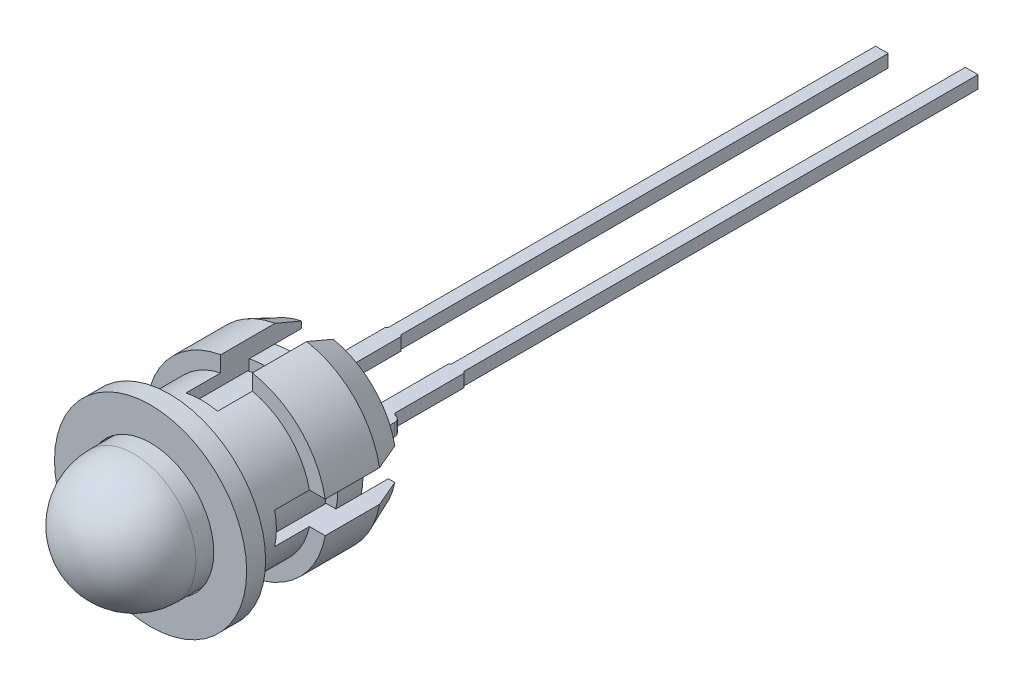
from build123d import *

# Parameters (mm, degrees)
EXTRUDE1_DEPTH          = 0.254
EXTRUDE1_DEPTH_BACK     = 0.254
CUT_EXTRUDE_THIN2_START = -27.675950193
SKETCH5_W               = 1.27
SKETCH5_H               = 8.860157491
CUT_EXTRUDE_THIN2_DEPTH = 31.231950193
CIRPATTERN2_COUNT       = 2
CIRPATTERN2_ANGLE       = 90


with BuildPart() as part:
    # Sketch1 → Revolve1 (revolve)
    with BuildSketch(Plane(origin=(0, 0, 0), x_dir=(0, 0, -1), z_dir=(1, 0, 0))):
        with BuildLine():
            Line((0, 0), (0, 2.921))
            Line((0, 2.921), (-1.016, 2.921))
            Line((-1.016, 2.921), (-1.016, 2.5))
            Line((-1.016, 2.5), (-6.2884, 2.5))
            ThreePointArc((-6.2884, 2.5), (-8.056166953, 1.767766953), (-8.7884, 0))
            Line((-8.7884, 0), (0, 0))
        make_face()
    revolve(axis=Axis((0, 0, 68.7324), (0, 0, -1)))

    # Sketch3 → Extrude1 (add, two sides: drawn at the far end of the back side and taken through both)
    with BuildSketch(Plane(origin=(0, 0, 0), x_dir=(1, 0, 0), z_dir=(0, 1, 0)).offset(-EXTRUDE1_DEPTH_BACK)):
        with BuildLine():
            Line((0.8382, 0), (1.7018, 0))
            Line((1.7018, 0), (1.7018, 1.740996518))
            ThreePointArc((1.7018, 1.740996518), (1.720043698, 1.806579036), (1.769533333, 1.853319544))
            ThreePointArc((1.769533333, 1.853319544), (1.868512605, 1.946800561), (1.905, 2.077965597))
            Line((1.905, 2.077965597), (1.905, 2.289552623))
            ThreePointArc((1.905, 2.289552623), (1.844995704, 2.453508918), (1.693333333, 2.54))
            ThreePointArc((1.693333333, 2.54), (1.617502148, 2.583245541), (1.5875, 2.665223689))
            Line((1.5875, 2.665223689), (1.5875, 5.3975))
            Line((1.5875, 5.3975), (1.524, 5.461))
            Line((1.524, 5.461), (1.524, 26.1112))
            Line((1.524, 26.1112), (1.016, 26.1112))
            Line((1.016, 26.1112), (1.016, 5.461))
            Line((1.016, 5.461), (0.9525, 5.3975))
            Line((0.9525, 5.3975), (0.9525, 2.665223689))
            ThreePointArc((0.9525, 2.665223689), (0.922497852, 2.583245541), (0.846666667, 2.54))
            ThreePointArc((0.846666667, 2.54), (0.695004296, 2.453508918), (0.635, 2.289552623))
            Line((0.635, 2.289552623), (0.635, 2.077965597))
            ThreePointArc((0.635, 2.077965597), (0.671487395, 1.946800561), (0.770466667, 1.853319544))
            ThreePointArc((0.770466667, 1.853319544), (0.819956302, 1.806579036), (0.8382, 1.740996518))
            Line((0.8382, 1.740996518), (0.8382, 0))
        make_face()
        with BuildLine():
            Line((-1.5875, 5.3975), (-1.524, 5.461))
            Line((-1.524, 5.461), (-1.524, 25.0444))
            Line((-1.524, 25.0444), (-1.016, 25.0444))
            Line((-1.016, 25.0444), (-1.016, 5.461))
            Line((-1.016, 5.461), (-0.9525, 5.3975))
            Line((-0.9525, 5.3975), (-0.9525, 2.665223689))
            ThreePointArc((-0.9525, 2.665223689), (-0.922497852, 2.583245541), (-0.846666667, 2.54))
            ThreePointArc((-0.846666667, 2.54), (-0.695004296, 2.453508918), (-0.635, 2.289552623))
            Line((-0.635, 2.289552623), (-0.635, 2.077965597))
            ThreePointArc((-0.635, 2.077965597), (-0.671487395, 1.946800561), (-0.770466667, 1.853319544))
            ThreePointArc((-0.770466667, 1.853319544), (-0.819956302, 1.806579036), (-0.8382, 1.740996518))
            Line((-0.8382, 1.740996518), (-0.8382, 0))
            Line((-0.8382, 0), (-1.7018, 0))
            Line((-1.7018, 0), (-1.7018, 1.740996518))
            ThreePointArc((-1.7018, 1.740996518), (-1.720043698, 1.806579036), (-1.769533333, 1.853319544))
            ThreePointArc((-1.769533333, 1.853319544), (-1.868512605, 1.946800561), (-1.905, 2.077965597))
            Line((-1.905, 2.077965597), (-1.905, 2.289552623))
            ThreePointArc((-1.905, 2.289552623), (-1.844995704, 2.453508918), (-1.693333333, 2.54))
            ThreePointArc((-1.693333333, 2.54), (-1.617502148, 2.583245541), (-1.5875, 2.665223689))
            Line((-1.5875, 2.665223689), (-1.5875, 5.3975))
        make_face()
    extrude(amount=EXTRUDE1_DEPTH + EXTRUDE1_DEPTH_BACK)


with BuildPart() as body_2:
    # Sketch4 → Revolve3 (revolve)
    with BuildSketch(Plane(origin=(0, 0, 0), x_dir=(0, 0, -1), z_dir=(1, 0, 0))):
        Polygon((-5.6134, 3.8608), (-5.6134, 2.54), (-1.016, 2.54), (-1.016, 2.921), (1.0922, 2.921), (1.0922, 3.175), (0.0254, 3.6195), (-2.159, 3.6195), (-2.159, 2.9972), (-4.8514, 2.9972), (-4.8514, 3.8608), align=None)
    revolve(axis=Axis((0, 0, 10.223161333), (0, 0, -1)))

    # Sketch5 → Cut-Extrude-Thin2 (cut)
    with BuildSketch(Plane.XY.offset(CUT_EXTRUDE_THIN2_START)):
        with Locations((0, -0.066617726)):
            Rectangle(SKETCH5_W, SKETCH5_H)
    cut_extrude_thin2 = extrude(amount=CUT_EXTRUDE_THIN2_DEPTH, mode=Mode.SUBTRACT)

    # CirPattern2: Cut-Extrude-Thin2 ×2 about axis
    cirpattern2_axis = Axis((0, 0, 68.7324), (0, 0, -1))
    for i in range(1, CIRPATTERN2_COUNT):
        add(cut_extrude_thin2.rotate(cirpattern2_axis, i * CIRPATTERN2_ANGLE / (CIRPATTERN2_COUNT - 1)), mode=Mode.SUBTRACT)


solid = Compound([part.part, body_2.part])
